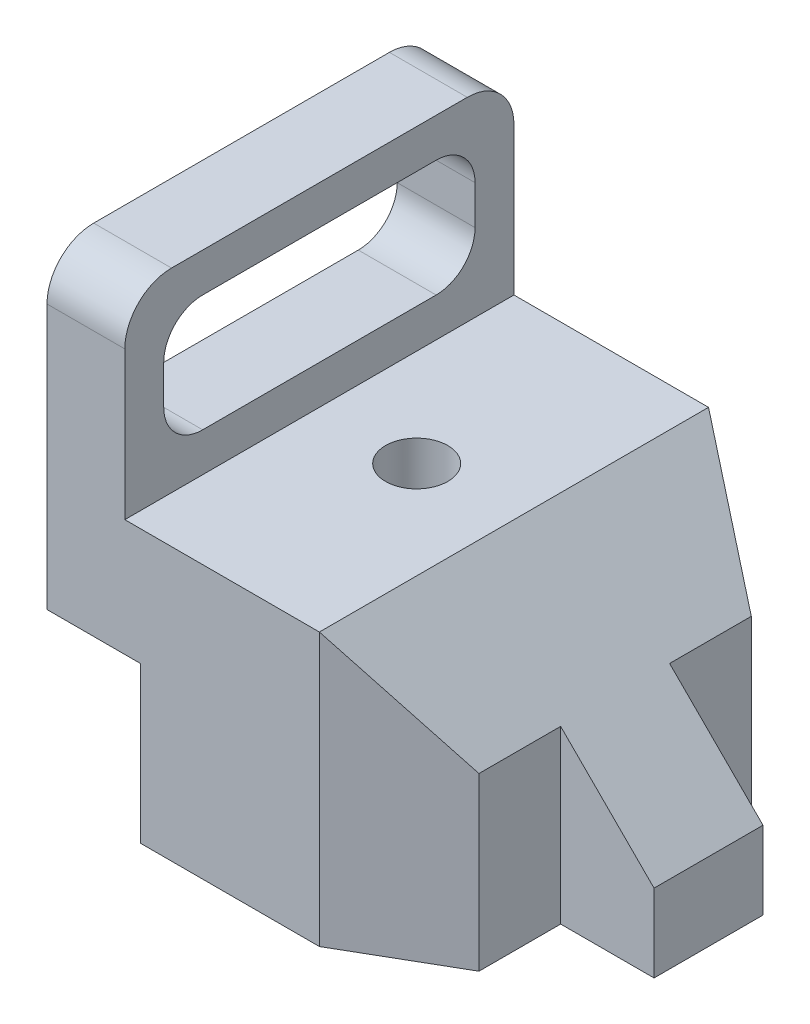
from build123d import *

# Parameters (mm, degrees)
BOSS_EXTRUDE1_DEPTH = 25
SKETCH3_R           = 4
CUT_EXTRUDE2_DEPTH  = 89.459030065
CUT_EXTRUDE3_DEPTH  = 89.459030065
CUT_EXTRUDE4_DEPTH  = 89.459030065
CUT_EXTRUDE5_DEPTH  = 83.006097334
FILLET1_R           = 6


with BuildPart() as part:
    # Sketch2 → Boss-Extrude1 (new, symmetric)
    with BuildSketch(Plane.XY):
        Polygon((0, 10), (-25, 35), (-50, 35), (-50, 60), (-60, 60), (-60, 20), (-48, 20), (-48, 0), (0, 0), align=None)
    extrude(amount=BOSS_EXTRUDE1_DEPTH, both=True)

    # Sketch3 → Cut-Extrude2 (cut, through all)
    with BuildSketch(Plane(origin=(0, 0, 0), x_dir=(1, 0, 0), z_dir=(0, 1, 0))):
        with Locations((-37.5, 0)):
            Circle(SKETCH3_R)
    extrude(amount=CUT_EXTRUDE2_DEPTH, mode=Mode.SUBTRACT)

    # Sketch3_5 → Cut-Extrude3 (cut, through all)
    with BuildSketch(Plane(origin=(0, 0, 0), x_dir=(1, 0, 0), z_dir=(0, 1, 0))):
        Polygon((0, 25), (-25, 25), (0, 10.56624327), align=None)
        Polygon((0, -10.56624327), (-25, -25), (0, -25), align=None)
    extrude(amount=CUT_EXTRUDE3_DEPTH, mode=Mode.SUBTRACT)

    # Sketch3_6 → Cut-Extrude4 (cut, through all)
    with BuildSketch(Plane(origin=(0, 0, 0), x_dir=(1, 0, 0), z_dir=(0, 1, 0))):
        Polygon((0, 10.56624327), (-12, 17.494446501), (-12, 7), (0, 7), align=None)
        Polygon((-12, -7), (-12, -17.494446501), (0, -10.56624327), (0, -7), align=None)
    extrude(amount=CUT_EXTRUDE4_DEPTH, mode=Mode.SUBTRACT)

    # Sketch6 → Cut-Extrude5 (cut, through all)
    with BuildSketch(Plane(origin=(-50, 0, 0), x_dir=(0, 0, -1), z_dir=(1, 0, 0))):
        with BuildLine():
            Line((-15, 55), (15, 55))
            ThreePointArc((15, 55), (18.535533906, 53.535533906), (20, 50))
            Line((20, 50), (20, 45))
            ThreePointArc((20, 45), (18.535533906, 41.464466094), (15, 40))
            Line((15, 40), (-15, 40))
            ThreePointArc((-15, 40), (-18.535533906, 41.464466094), (-20, 45))
            Line((-20, 45), (-20, 50))
            ThreePointArc((-20, 50), (-18.535533906, 53.535533906), (-15, 55))
        make_face()
    extrude(amount=-CUT_EXTRUDE5_DEPTH, mode=Mode.SUBTRACT)

    # Fillet1
    fillet1_edges = [part.edges().sort_by_distance(p)[0] for p in [
        (-55, 60, -25),
        (-55, 60, 25),
    ]]
    fillet(fillet1_edges, radius=FILLET1_R)


solid = part.part
